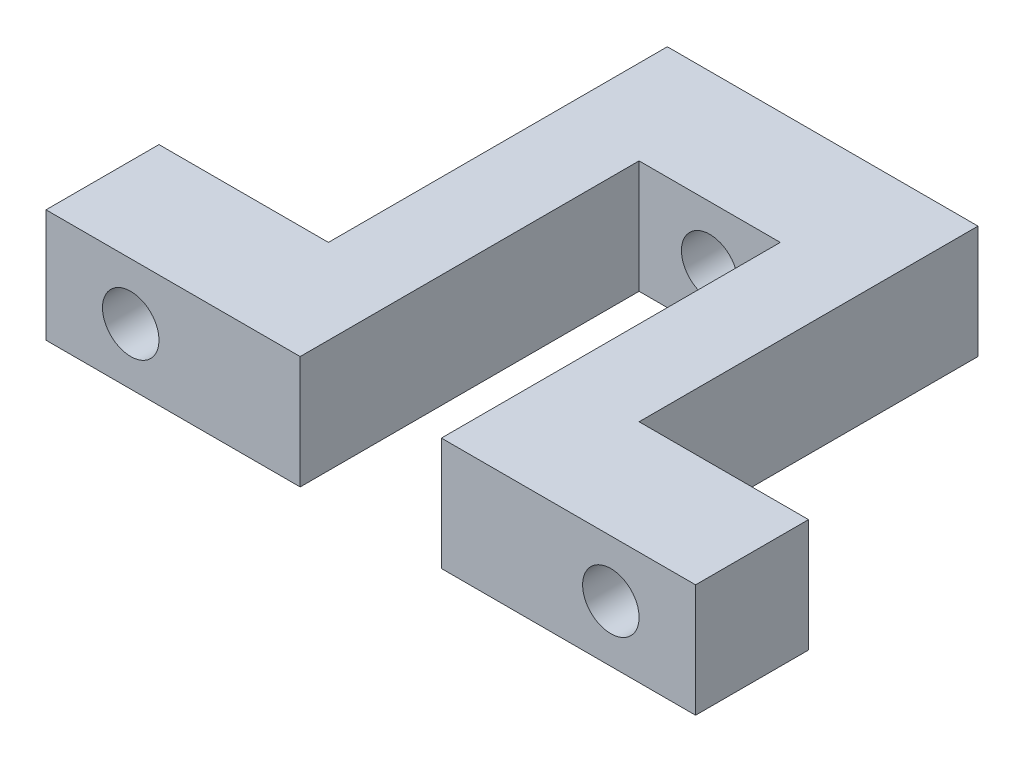
from build123d import *

# Parameters (mm, degrees)
BOSS_EXTRUDE1_DEPTH              = 20
M10X1_0_TAPPED_HOLE1_D           = 9
M10X1_0_TAPPED_HOLE1_DEPTH       = 23
M10X1_0_TAPPED_HOLE1_CBORE_D     = 10
M10X1_0_TAPPED_HOLE1_CBORE_DEPTH = 20
M10X1_0_TAPPED_HOLE1_TIP         = 2.703872786
M10X1_0_TAPPED_HOLE2_D           = 9
M10X1_0_TAPPED_HOLE2_DEPTH       = 23
M10X1_0_TAPPED_HOLE2_CBORE_D     = 10
M10X1_0_TAPPED_HOLE2_CBORE_DEPTH = 20
M10X1_0_TAPPED_HOLE2_TIP         = 2.703872786


with BuildPart() as part:
    # Sketch1 → Boss-Extrude1 (new body)
    with BuildSketch(Plane(origin=(0, 0, 0), x_dir=(1, 0, 0), z_dir=(0, 1, 0))):
        Polygon((-70, -38.848444635), (-70, -18.848444635), (-40, -18.848444635), (-40, 41.151555365), (15, 41.151555365), (15, -18.848444635), (45, -18.848444635), (45, -38.848444635), (0, -38.848444635), (0, 21.151555365), (-25, 21.151555365), (-25, -38.848444635), align=None)
    extrude(amount=BOSS_EXTRUDE1_DEPTH)

    # M10x1.0 Tapped Hole1
    with Locations(Plane(origin=(-12.5, 10, -41.151555365), x_dir=(-1, 0, 0), z_dir=(0, 0, -1))):
        with Locations((0, 0)):
            CounterBoreHole(M10X1_0_TAPPED_HOLE1_D / 2, M10X1_0_TAPPED_HOLE1_CBORE_D / 2, M10X1_0_TAPPED_HOLE1_CBORE_DEPTH, depth=M10X1_0_TAPPED_HOLE1_DEPTH)
            with Locations((0, 0, -(M10X1_0_TAPPED_HOLE1_DEPTH + M10X1_0_TAPPED_HOLE1_TIP / 2))):  # 118° drill point
                Cone(0, M10X1_0_TAPPED_HOLE1_D / 2, M10X1_0_TAPPED_HOLE1_TIP, mode=Mode.SUBTRACT)

    # M10x1.0 Tapped Hole2
    with Locations(Plane(origin=(30, 10, 18.848444635), x_dir=(-1, 0, 0), z_dir=(0, 0, -1))):
        with Locations((0, 0), (85, 0)):
            CounterBoreHole(M10X1_0_TAPPED_HOLE2_D / 2, M10X1_0_TAPPED_HOLE2_CBORE_D / 2, M10X1_0_TAPPED_HOLE2_CBORE_DEPTH, depth=M10X1_0_TAPPED_HOLE2_DEPTH)
            with Locations((0, 0, -(M10X1_0_TAPPED_HOLE2_DEPTH + M10X1_0_TAPPED_HOLE2_TIP / 2))):  # 118° drill point
                Cone(0, M10X1_0_TAPPED_HOLE2_D / 2, M10X1_0_TAPPED_HOLE2_TIP, mode=Mode.SUBTRACT)


solid = part.part
